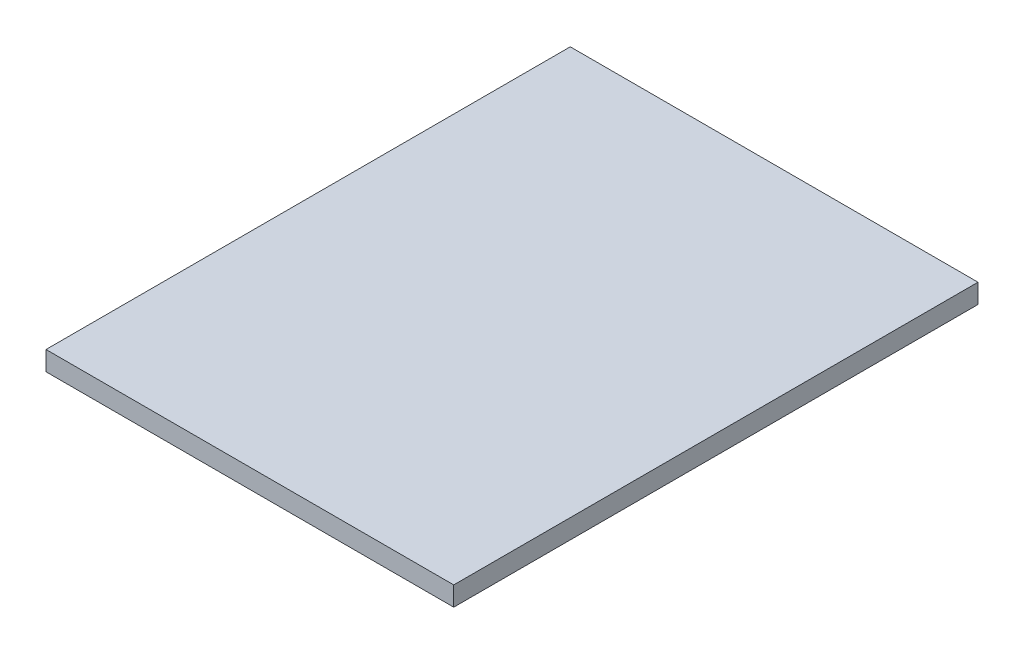
from build123d import *

# Parameters (mm, degrees)
SKETCH1_W           = 53.594
SKETCH1_H           = 68.9102
BOSS_EXTRUDE1_DEPTH = 2.54


with BuildPart() as part:
    # Sketch1 → Boss-Extrude1 (new body)
    with BuildSketch(Plane(origin=(0, 0, 0), x_dir=(1, 0, 0), z_dir=(0, 1, 0))):
        with Locations((26.797, 34.4551)):
            Rectangle(SKETCH1_W, SKETCH1_H)
    extrude(amount=BOSS_EXTRUDE1_DEPTH)


solid = part.part
